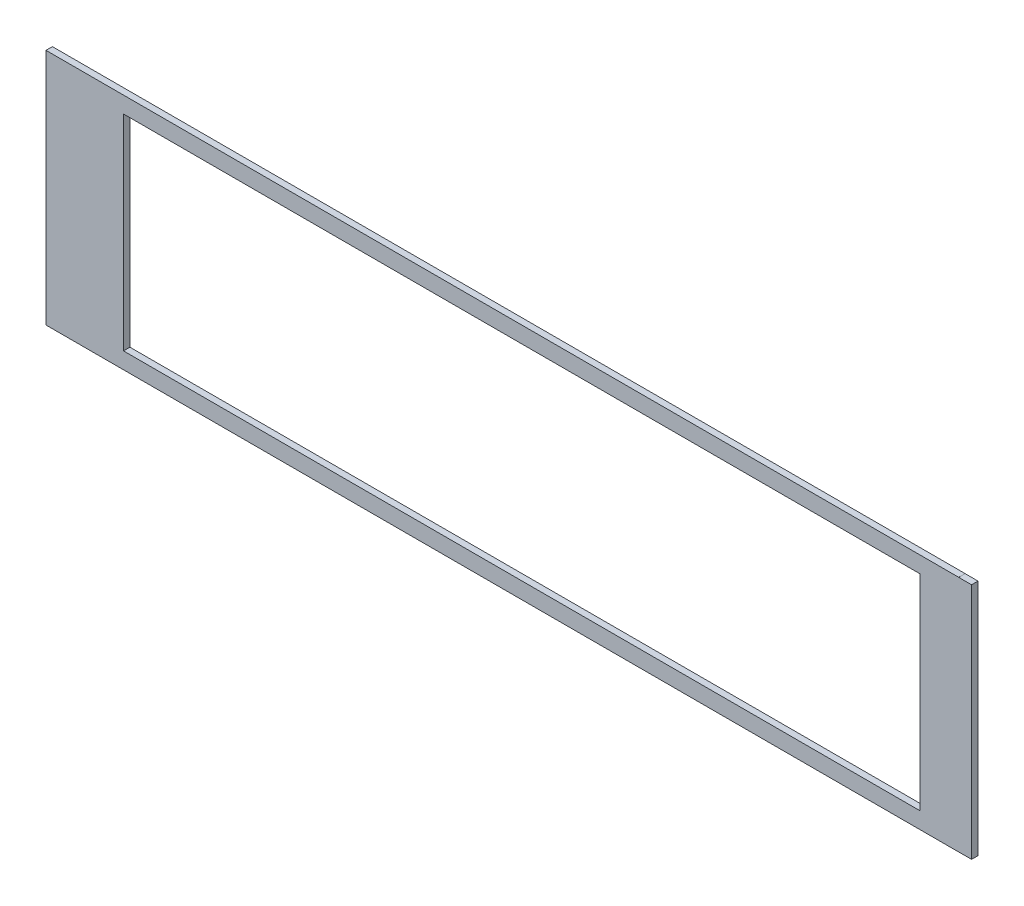
from build123d import *

# Parameters (mm, degrees)
SKETCH1_W           = 393.4968
SKETCH1_H           = 101.3968
BOSS_EXTRUDE1_DEPTH = 3.175


with BuildPart() as part:
    # Sketch1 → Boss-Extrude1 (new body)
    with BuildSketch(Plane.XY):
        Polygon((222.3516, 58.785125), (-228.7016, 58.785125), (-228.7016, -58.785125), (222.3516, -58.785125), (222.3516, -58.759725), (228.7016, -58.759725), (228.7016, 58.759725), (222.3516, 58.759725), align=None)
        with Locations((6.35, 0)):
            Rectangle(SKETCH1_W, SKETCH1_H, mode=Mode.SUBTRACT)
    extrude(amount=BOSS_EXTRUDE1_DEPTH)


solid = part.part
